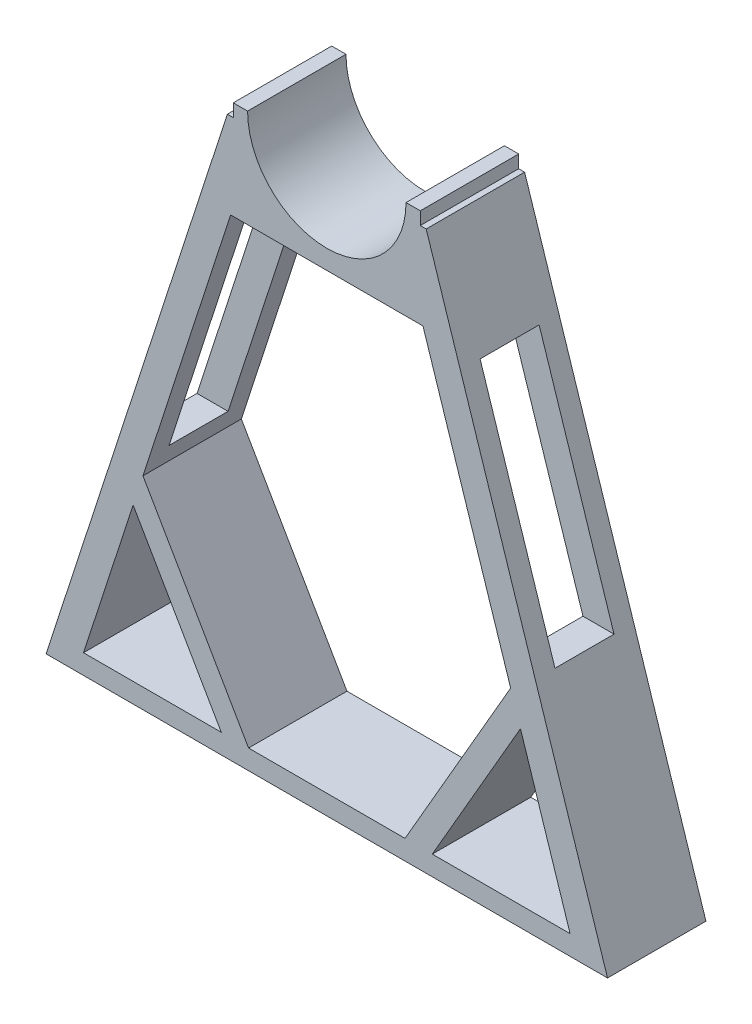
from build123d import *

# Parameters (mm, degrees)
BOSS_EXTRUDE1_DEPTH     = 50
CUT_EXTRUDE1_DEPTH      = 80
SKETCH4_W               = 30
SKETCH4_H               = 117.064102809
CUT_EXTRUDE2_DEPTH      = 11.624305452
CUT_EXTRUDE2_DEPTH_BACK = 260


with BuildPart() as part:
    # Sketch1 → Boss-Extrude1 (new body)
    with BuildSketch(Plane.XY):
        with BuildLine():
            Line((-40.25, 0), (-47.5, 0))
            Line((-47.5, 0), (-47.5, -6.5))
            Line((-47.5, -6.5), (-50.5, -6.5))
            Line((-50.5, -6.5), (-142.624305452, -290))
            Line((-142.624305452, -290), (142.624305452, -290))
            Line((142.624305452, -290), (50.5, -6.5))
            Line((50.5, -6.5), (47.5, -6.5))
            Line((47.5, -6.5), (47.5, 0))
            Line((47.5, 0), (40.25, 0))
            ThreePointArc((40.25, 0), (0, -40.25), (-40.25, 0))
        make_face()
    extrude(amount=BOSS_EXTRUDE1_DEPTH)

    # Sketch2 → Cut-Extrude1 (cut)
    with BuildSketch(Plane.XY.offset(50)):
        Polygon((-123.602681001, -280), (-98.393052146, -202.420801488), (-53.602681001, -280), align=None)
        Polygon((48.863385573, -50), (93.402839801, -187.064102809), (39.746274541, -280), (-39.746274541, -280), (-93.402839801, -187.064102809), (-48.863385573, -50), align=None)
        Polygon((123.602681001, -280), (53.602681001, -280), (98.393052146, -202.420801488), align=None)
    extrude(amount=-CUT_EXTRUDE1_DEPTH, mode=Mode.SUBTRACT)

    # Sketch4 → Cut-Extrude2 (cut, two sides)
    with BuildSketch(Plane(origin=(132, 0, 0), x_dir=(0, 0, -1), z_dir=(1, 0, 0))) as cut_extrude2_sk:
        with Locations((-25, -118.532051405)):
            Rectangle(SKETCH4_W, SKETCH4_H)
    extrude(amount=CUT_EXTRUDE2_DEPTH, mode=Mode.SUBTRACT)
    extrude(cut_extrude2_sk.sketch, amount=-CUT_EXTRUDE2_DEPTH_BACK, mode=Mode.SUBTRACT)


solid = part.part
